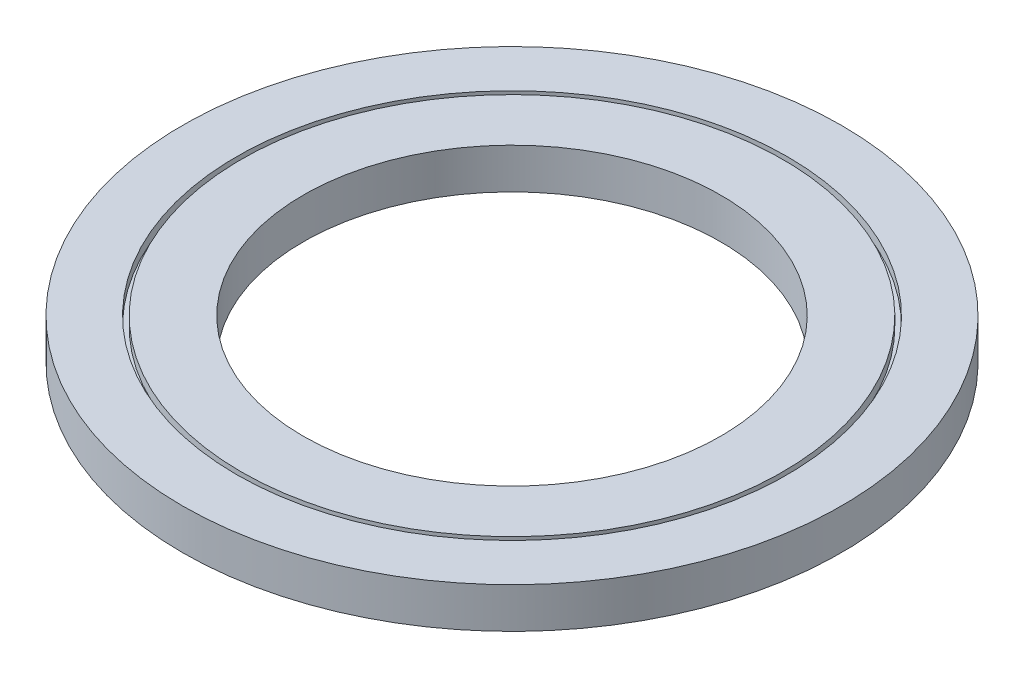
from build123d import *

# Parameters (mm, degrees)
SKETCH1_R           = 70
SKETCH1_R_2         = 44.35
BOSS_EXTRUDE1_DEPTH = 8.6
SKETCH2_R           = 58.5
SKETCH2_R_2         = 57.5
CUT_EXTRUDE1_DEPTH  = 2


with BuildPart() as part:
    # Sketch1 → Boss-Extrude1 (new body)
    with BuildSketch(Plane(origin=(0, 0, 0), x_dir=(1, 0, 0), z_dir=(0, 1, 0))):
        Circle(SKETCH1_R)
        Circle(SKETCH1_R_2, mode=Mode.SUBTRACT)
    extrude(amount=BOSS_EXTRUDE1_DEPTH)

    # Sketch2 → Cut-Extrude1 (cut)
    with BuildSketch(Plane(origin=(0, 8.6, 0), x_dir=(1, 0, 0), z_dir=(0, 1, 0))):
        Circle(SKETCH2_R)
        Circle(SKETCH2_R_2, mode=Mode.SUBTRACT)
    extrude(amount=-CUT_EXTRUDE1_DEPTH, mode=Mode.SUBTRACT)


solid = part.part
